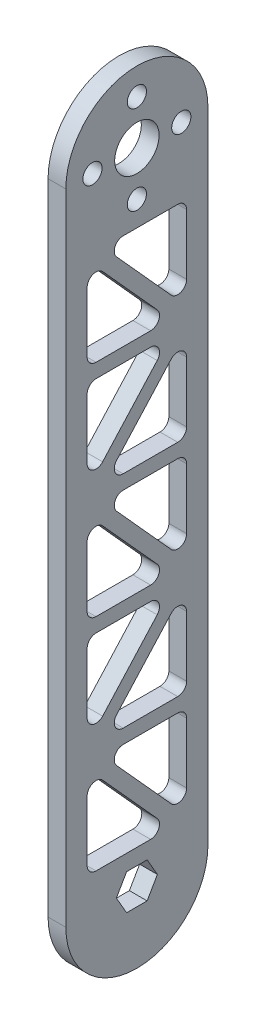
from build123d import *

# Parameters (mm, degrees)
SKETCH1_R           = 7.9375
SKETCH1_R_2         = 3.429
BOSS_EXTRUDE1_DEPTH = 6.35
CUT_EXTRUDE2_DEPTH  = 7.35
FILLET2_R           = 3.175


with BuildPart() as part:
    # Sketch1 → Boss-Extrude1 (new body)
    with BuildSketch(Plane(origin=(0, 0, 0), x_dir=(0, 0, -1), z_dir=(1, 0, 0))):
        with BuildLine():
            Line((-25.4, 228.6), (-25.4, 0))
            ThreePointArc((-25.4, 0), (0, -25.4), (25.4, 0))
            Line((25.4, 0), (25.4, 228.6))
            ThreePointArc((25.4, 228.6), (0, 254), (-25.4, 228.6))
        make_face()
        with Locations((0, 228.6)):
            Circle(SKETCH1_R, mode=Mode.SUBTRACT)
        with Locations((0, 212.725)):
            Circle(SKETCH1_R_2, mode=Mode.SUBTRACT)
        with Locations((-15.875, 228.6)):
            Circle(SKETCH1_R_2, mode=Mode.SUBTRACT)
        with Locations((0, 244.475)):
            Circle(SKETCH1_R_2, mode=Mode.SUBTRACT)
        with Locations((15.875, 228.6)):
            Circle(SKETCH1_R_2, mode=Mode.SUBTRACT)
        Polygon((7.332348419, 0), (3.666174209, 6.35), (-3.666174209, 6.35), (-7.332348419, 0), (-3.666174209, -6.35), (3.666174209, -6.35), align=None, mode=Mode.SUBTRACT)
    extrude(amount=BOSS_EXTRUDE1_DEPTH)

    # Sketch3 → Cut-Extrude2 (cut, through all)
    with BuildSketch(Plane(origin=(6.35, 0, 0), x_dir=(0, 0, -1), z_dir=(1, 0, 0))):
        Polygon((-12.06309933, 203.835), (17.78, 170.794425741), (17.78, 203.835), align=None)
        Polygon((-17.78, 202.585574259), (-17.78, 169.545), (12.06309933, 169.545), align=None)
        Polygon((12.063099331, 164.465), (-17.78, 164.465), (-17.78, 131.424425736), align=None)
        Polygon((17.78, 163.215574258), (-12.063099331, 130.174999995), (17.78, 130.174999995), align=None)
        Polygon((12.063099331, 90.804999989), (-17.78, 123.845574253), (-17.78, 90.804999989), align=None)
        Polygon((17.78, 125.094999995), (-12.063099331, 125.094999995), (17.78, 92.054425731), align=None)
        Polygon((17.78, 51.434999984), (17.78, 84.475574248), (-12.063099331, 51.434999984), align=None)
        Polygon((12.063099331, 85.724999989), (-17.78, 85.724999989), (-17.78, 52.684425726), align=None)
        Polygon((17.78, 46.354999984), (-12.063099329, 46.354999984), (17.78, 13.31442574), align=None)
        Polygon((12.063099329, 12.065), (-17.78, 45.105574244), (-17.78, 12.065), align=None)
    extrude(amount=-CUT_EXTRUDE2_DEPTH, mode=Mode.SUBTRACT)

    # Fillet2
    fillet2_edges = [part.edges().sort_by_distance(p)[0] for p in [
        (3.175, 52.684425726, 17.78),
        (3.175, 85.724999989, 17.78),
        (3.175, 46.354999984, 12.063099329),
        (3.175, 46.354999984, -17.78),
        (3.175, 13.31442574, -17.78),
        (3.175, 169.545, -12.06309933),
        (3.175, 169.545, 17.78),
        (3.175, 202.585574259, 17.78),
        (3.175, 164.465, -12.063099331),
        (3.175, 131.424425736, 17.78),
        (3.175, 164.465, 17.78),
        (3.175, 130.174999995, 12.063099331),
        (3.175, 163.215574258, -17.78),
        (3.175, 130.174999995, -17.78),
        (3.175, 90.804999989, -12.063099331),
        (3.175, 90.804999989, 17.78),
        (3.175, 123.845574253, 17.78),
        (3.175, 12.065, 17.78),
        (3.175, 45.105574244, 17.78),
        (3.175, 12.065, -12.063099329),
        (3.175, 203.835, 12.06309933),
        (3.175, 203.835, -17.78),
        (3.175, 170.794425741, -17.78),
        (3.175, 125.094999995, 12.063099331),
        (3.175, 125.094999995, -17.78),
        (3.175, 92.054425731, -17.78),
        (3.175, 51.434999984, 12.063099331),
        (3.175, 84.475574248, -17.78),
        (3.175, 51.434999984, -17.78),
        (3.175, 85.724999989, -12.063099331),
    ]]
    fillet(fillet2_edges, radius=FILLET2_R)


solid = part.part
